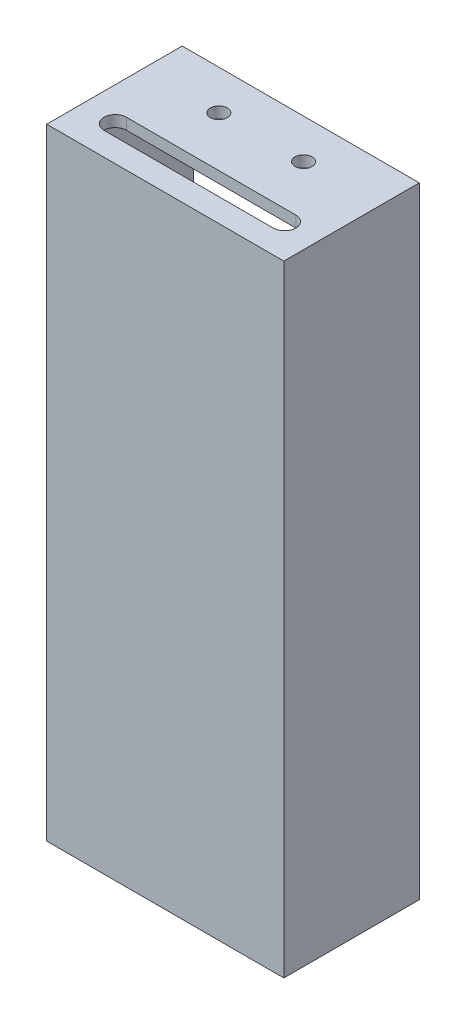
from build123d import *

# Parameters (mm, degrees)
SKETCH_1_W          = 38
SKETCH_1_H          = 106
EXTRUDE_1_DEPTH     = 2
SKETCH_2_W          = 42
SKETCH_2_H          = 110
SKETCH_2_W_2        = 38
SKETCH_2_H_2        = 39
SKETCH_2_H_3        = 65
EXTRUDE_5_DEPTH     = 24
SKETCH_9_W          = 6
SKETCH_9_H          = 8
CUT_EXTRUDE_2_DEPTH = 20
SKETCH_10_R         = 1.5
CUT_EXTRUDE_3_DEPTH = 20
SKETCH_12_W         = 38
SKETCH_12_H         = 65
EXTRUDE_7_DEPTH     = 2
SKETCH_13_W         = 38
SKETCH_13_H         = 20
CUT_EXTRUDE_4_DEPTH = 2


with BuildPart() as part:
    # 草图1 → 凸台-拉伸1 (new body)
    with BuildSketch(Plane.XY):
        with Locations((-19, 20.675324675)):
            Rectangle(SKETCH_1_W, SKETCH_1_H)
    extrude(amount=EXTRUDE_1_DEPTH)

    # 草图2 → 凸台-拉伸5 (add)
    with BuildSketch(Plane.XY.offset(2)):
        with Locations((-19, 20.675324675)):
            Rectangle(SKETCH_2_W, SKETCH_2_H)
        with Locations((-19, 54.175324675)):
            Rectangle(SKETCH_2_W_2, SKETCH_2_H_2, mode=Mode.SUBTRACT)
        with Locations((-19, 0.175324675)):
            Rectangle(SKETCH_2_W_2, SKETCH_2_H_3, mode=Mode.SUBTRACT)
    extrude(amount=-EXTRUDE_5_DEPTH)

    # 草图9 → 切除-拉伸2 (cut)
    with BuildSketch(Plane.ZY.offset(40)):
        with Locations((-7, 26.675324675)):
            Rectangle(SKETCH_9_W, SKETCH_9_H)
        with Locations((-7, 53.675324675)):
            Rectangle(SKETCH_9_W, SKETCH_9_H)
    extrude(amount=-CUT_EXTRUDE_2_DEPTH, mode=Mode.SUBTRACT)

    # 草图10 → 切除-拉伸3 (cut)
    with BuildSketch(Plane(origin=(0, 75.675324675, 0), x_dir=(1, 0, 0), z_dir=(0, 1, 0))):
        with Locations((-26.5, 15)):
            Circle(SKETCH_10_R)
        with Locations((-11.5, 15)):
            Circle(SKETCH_10_R)
        with BuildLine():
            Line((-34, 6.130920254), (-4, 6.130920254))
            ThreePointArc((-4, 6.130920254), (-2, 4.130920254), (-4, 2.130920254))
            Line((-4, 2.130920254), (-34, 2.130920254))
            ThreePointArc((-34, 2.130920254), (-36, 4.130920254), (-34, 6.130920254))
        make_face()
    extrude(amount=-CUT_EXTRUDE_3_DEPTH, mode=Mode.SUBTRACT)

    # 草图12 → 凸台-拉伸7 (add)
    with BuildSketch(Plane(origin=(0, 0, -22), x_dir=(-1, 0, 0), z_dir=(0, 0, -1))):
        with Locations((19, 0.175324675)):
            Rectangle(SKETCH_12_W, SKETCH_12_H)
    extrude(amount=-EXTRUDE_7_DEPTH)

    # 草图13 → 切除-拉伸4 (cut)
    with BuildSketch(Plane.XZ.offset(34.324675325)):
        with Locations((-19, -10)):
            Rectangle(SKETCH_13_W, SKETCH_13_H)
    extrude(amount=-CUT_EXTRUDE_4_DEPTH, mode=Mode.SUBTRACT)


solid = part.part
